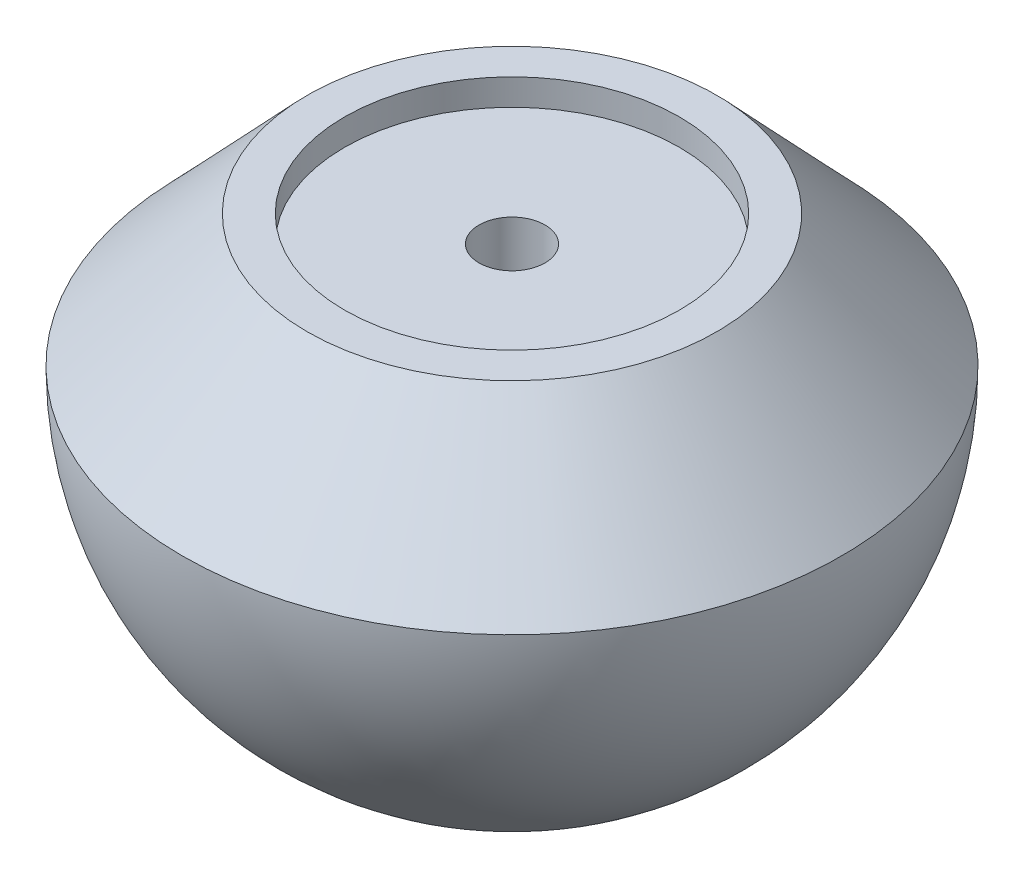
from build123d import *

# Parameters (mm, degrees)
FILLET1_R = 0.5


with BuildPart() as part:
    # Sketch1 → Revolve1 (revolve)
    with BuildSketch(Plane.XY):
        with BuildLine():
            Line((-15.538461538, 10), (-25, 0))
            ThreePointArc((-25, 0), (-21.46926352, -12.809009482), (-11.874342087, -22))
            Line((-11.874342087, -22), (-5, -22))
            Line((-5, -22), (-5, -12))
            Line((-5, -12), (-2.5, -12))
            Line((-2.5, -12), (-2.5, 8))
            Line((-2.5, 8), (-12.7, 8))
            Line((-12.7, 8), (-12.7, 10))
            Line((-12.7, 10), (-15.538461538, 10))
        make_face()
    revolve(axis=Axis((0, 0, 0), (0, -1, 0)))

    # Fillet1
    fillet1_edges = [part.edges().sort_by_distance(p)[0] for p in [
        (5, -22, 0),
        (11.874342087, -22, 0),
    ]]
    fillet(fillet1_edges, radius=FILLET1_R)


solid = part.part
